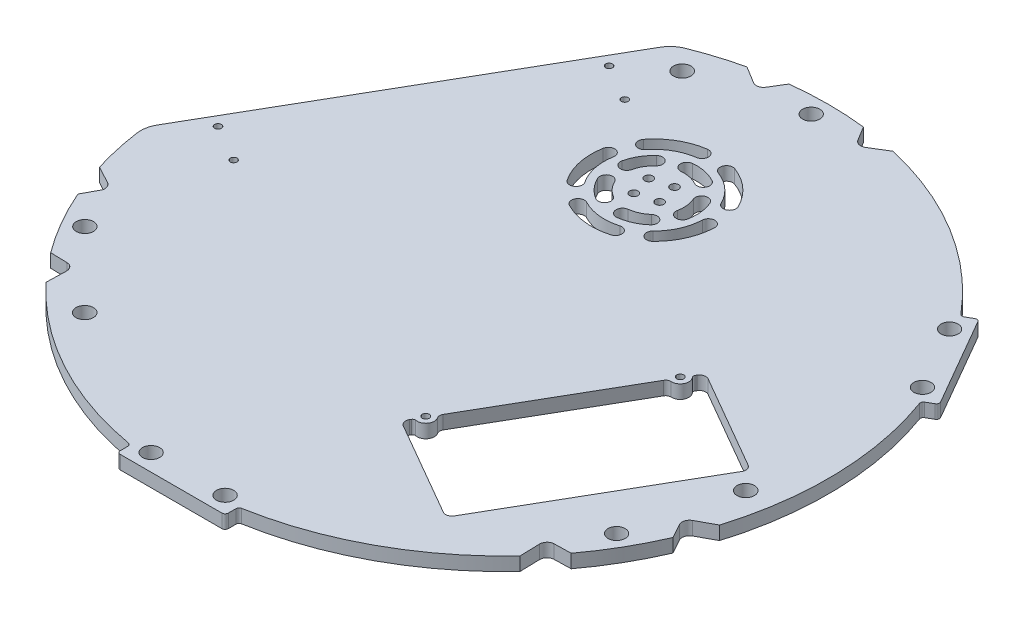
from build123d import *

# Parameters (mm, degrees)
SKETCH1_R               = 152.4
BOSS_EXTRUDE1_DEPTH     = 6.35
SKETCH2_R               = 4.05
CUT_EXTRUDE1_DEPTH      = 7.35
SKETCH3_W               = 50.8
SKETCH3_H               = 6.35
BOSS_EXTRUDE2_DEPTH     = 6.35
SKETCH4_R               = 4.05
CUT_EXTRUDE2_DEPTH      = 7.35
FILLET1_R               = 1.5
CUT_EXTRUDE3_DEPTH      = 1
CUT_EXTRUDE3_DEPTH_BACK = 7.35
SKETCH7_R               = 4.1
CUT_EXTRUDE4_DEPTH      = 7.35
CUT_EXTRUDE5_DEPTH      = 7.35
CIRPATTERN1_COUNT       = 3
CUT_EXTRUDE6_DEPTH      = 7.3500001
FILLET4_R               = 12.7
FILLET1_OF_MIRROR1_R    = 1.5
SKETCH13_R              = 1.6
CUT_EXTRUDE8_DEPTH      = 25.4
SKETCH17_R              = 1.950000002
CUT_EXTRUDE12_DEPTH     = 79.2000001
SKETCH18_R              = 1.6
CUT_EXTRUDE13_DEPTH     = 7.3500001
CUT_EXTRUDE14_DEPTH     = 7.3500001
BOSS_EXTRUDE4_DEPTH     = 6.35
SKETCH22_R              = 1.651
CUT_EXTRUDE15_DEPTH     = 6.35


with BuildPart() as part:
    # Sketch1 → Boss-Extrude1 (new body)
    with BuildSketch(Plane(origin=(0, 0, 0), x_dir=(1, 0, 0), z_dir=(0, 1, 0))):
        Circle(SKETCH1_R)
    extrude(amount=BOSS_EXTRUDE1_DEPTH)

    # Sketch2 → Cut-Extrude1 (cut, through all)
    with BuildSketch(Plane(origin=(0, 6.35, 0), x_dir=(1, 0, 0), z_dir=(0, 1, 0))):
        with Locations((0, 144.337567297)):
            Circle(SKETCH2_R)
        with Locations((125, -72.168783649)):
            Circle(SKETCH2_R)
        with Locations((-125, -72.168783649)):
            Circle(SKETCH2_R)
    extrude(amount=-CUT_EXTRUDE1_DEPTH, mode=Mode.SUBTRACT)

    # Sketch3 → Boss-Extrude2 (add)
    with BuildSketch(Plane(origin=(0, 6.35, 0), x_dir=(1, 0, 0), z_dir=(0, 1, 0))):
        with Locations((0, -153.443426491)):
            Rectangle(SKETCH3_W, SKETCH3_H)
    boss_extrude2 = extrude(amount=-BOSS_EXTRUDE2_DEPTH)

    # Sketch4 → Cut-Extrude2 (cut, through all)
    with BuildSketch(Plane(origin=(0, 6.35, 0), x_dir=(1, 0, 0), z_dir=(0, 1, 0))):
        with Locations((17.4, -148.618426491)):
            Circle(SKETCH4_R)
        with Locations((-17.4, -148.618426491)):
            Circle(SKETCH4_R)
    cut_extrude2 = extrude(amount=-CUT_EXTRUDE2_DEPTH, mode=Mode.SUBTRACT)

    # Fillet1
    fillet1_edges = [part.edges().sort_by_distance(p)[0] for p in [
        (-25.4, 3.175, 156.618426491),
        (-25.4, 3.175, 150.268426491),
        (25.4, 3.175, 150.268426491),
        (25.4, 3.175, 156.618426491),
    ]]
    fillet(fillet1_edges, radius=FILLET1_R)

    # Sketch5 → Cut-Extrude3 (cut, two sides)
    with BuildSketch(Plane.XZ) as cut_extrude3_sk:
        Polygon((349.002117149, -849.311004725), (-39.927688828, -175.664820195), (-166.196580997, 43.039316458), (-555.126386974, 716.685500989), (-1902.418756035, -61.174110966), (-998.290251911, -1627.170616679), align=None)
    extrude(amount=CUT_EXTRUDE3_DEPTH, mode=Mode.SUBTRACT)
    extrude(cut_extrude3_sk.sketch, amount=-CUT_EXTRUDE3_DEPTH_BACK, mode=Mode.SUBTRACT)

    # Sketch7 → Cut-Extrude4 (cut, through all)
    with BuildSketch(Plane(origin=(0, 6.35, 0), x_dir=(1, 0, 0), z_dir=(0, 1, 0))):
        with Locations((-89.990265356, -107.246222037)):
            Circle(SKETCH7_R)
        with Locations((-47.882820066, 131.55696691)):
            Circle(SKETCH7_R)
        with Locations((137.873085422, -24.310744873)):
            Circle(SKETCH7_R)
    extrude(amount=-CUT_EXTRUDE4_DEPTH, mode=Mode.SUBTRACT)

    # Sketch9 → Cut-Extrude5 (cut, through all)
    with BuildSketch(Plane(origin=(0, 0, 0), x_dir=(1, 0, 0), z_dir=(0, 1, 0))):
        with BuildLine():
            Line((-114.489650026, -91.049171744), (-125.485895746, -90.761804289))
            ThreePointArc((-125.485895746, -90.761804289), (-141.107525676, -81.468467934), (-141.344976081, -63.293071388))
            Line((-141.344976081, -63.293071388), (-136.095720736, -53.626359521))
            add(Edge.make_bspline(
                [(-136.095720736, -53.626359521), (-135.878459486, -53.226264313), (-135.609002334, -52.321508604), (-135.827738715, -50.483838058), (-136.77023444, -49.38544542), (-137.535647266, -48.969807981)],
                knots=[0, 0, 0, 0, 0.392699082, 0.785398163, 1.570796327, 1.570796327, 1.570796327, 1.570796327], degree=3))
            Line((-137.535647266, -48.969807981), (-159.97086473, -36.78694924))
            ThreePointArc((-159.97086473, -36.78694924), (-168.082788786, -97.042643352), (-111.843864935, -120.145358102))
            Line((-111.843864935, -120.145358102), (-111.176921363, -94.624460467))
            add(Edge.make_bspline(
                [(-114.489650026, -91.049171744), (-114.034526787, -91.061065586), (-113.116256782, -91.280086701), (-111.634155597, -92.388353236), (-111.154167531, -93.753774797), (-111.176921363, -94.624460467)],
                knots=[0, 0, 0, 0, 0.392699082, 0.785398163, 1.570796327, 1.570796327, 1.570796327, 1.570796327], degree=3))
        make_face()
    cut_extrude5 = extrude(amount=CUT_EXTRUDE5_DEPTH, mode=Mode.SUBTRACT)

    # CirPattern1: Cut-Extrude5 ×3 about axis
    cirpattern1_axis = Axis((0, 6.35, 0), (0, -1, 0))
    for i in range(1, CIRPATTERN1_COUNT):
        add(cut_extrude5.rotate(cirpattern1_axis, i * 360 / CIRPATTERN1_COUNT), mode=Mode.SUBTRACT)

    # Sketch10 → Cut-Extrude6 (cut, through all)
    with BuildSketch(Plane(origin=(0, 6.35, 0), x_dir=(1, 0, 0), z_dir=(0, 1, 0))):
        with BuildLine():
            Line((-19.005119762, -114.312397404), (14.631306921, -133.732397404))
            ThreePointArc((14.631306921, -133.732397404), (17.522407483, -134.113018013), (19.835863709, -132.337840615))
            Line((19.835863709, -132.337840615), (72.525863709, -41.076083564))
            ThreePointArc((72.525863709, -41.076083564), (72.906484319, -38.184983002), (71.131306921, -35.871526776))
            Line((71.131306921, -35.871526776), (37.494880238, -16.451526776))
            ThreePointArc((37.494880238, -16.451526776), (34.603779676, -16.070906166), (32.290323449, -17.846083564))
            Line((32.290323449, -17.846083564), (-20.399676551, -109.107840615))
            ThreePointArc((-20.399676551, -109.107840615), (-20.78029716, -111.998941177), (-19.005119762, -114.312397404))
        make_face()
    extrude(amount=-CUT_EXTRUDE6_DEPTH, mode=Mode.SUBTRACT)

    # Fillet4
    fillet4_edges = [part.edges().sort_by_distance(p)[0] for p in [
        (-60.619909652, 3.175, -139.824842406),
        (-151.40182043, 3.175, 17.414039469),
    ]]
    fillet(fillet4_edges, radius=FILLET4_R)

    # Mirror1: Boss-Extrude2, Cut-Extrude2 across plane
    add(boss_extrude2.mirror(Plane(origin=(0, 0, 0), x_dir=(0.866025404, 0, 0.5), z_dir=(0.5, 0, -0.866025404))))
    add(cut_extrude2.mirror(Plane(origin=(0, 0, 0), x_dir=(0.866025404, 0, 0.5), z_dir=(0.5, 0, -0.866025404))), mode=Mode.SUBTRACT)

    # Fillet1 of Mirror1
    fillet1_of_mirror1_edges = [part.edges().sort_by_distance(p)[0] for p in [
        (122.935536042, 3.175, -100.306258501),
        (117.436274728, 3.175, -97.131258501),
        (142.836274728, 3.175, -53.137167989),
        (148.335536042, 3.175, -56.312167989),
    ]]
    fillet(fillet1_of_mirror1_edges, radius=FILLET1_OF_MIRROR1_R)

    # Sketch13 → Cut-Extrude8 (cut)
    with BuildSketch(Plane(origin=(0, 6.35, 0), x_dir=(1, 0, 0), z_dir=(0, 1, 0))):
        with Locations((-134.469712618, -0.08676846)):
            Circle(SKETCH13_R)
        with Locations((-117.098901351, -10.115811022)):
            Circle(SKETCH13_R)
        with Locations((-67.159712618, 116.497571397)):
            Circle(SKETCH13_R)
        with Locations((-49.788901351, 106.468528836)):
            Circle(SKETCH13_R)
    extrude(amount=-CUT_EXTRUDE8_DEPTH, mode=Mode.SUBTRACT)

    # Sketch17 → Cut-Extrude12 (cut, through all)
    with BuildSketch(Plane(origin=(0, 78.2, 0), x_dir=(1, 0, 0), z_dir=(0, 1, 0))):
        with Locations((-12.025034048, 79.977465694)):
            Circle(SKETCH17_R)
        with Locations((-2.462856222, 82.539643521)):
            Circle(SKETCH17_R)
        with Locations((0.099321605, 72.977465694)):
            Circle(SKETCH17_R)
        with Locations((-9.462856222, 70.415287868)):
            Circle(SKETCH17_R)
        with BuildLine():
            ThreePointArc((15.134436246, 86.828999423), (19.149180016, 85.457200435), (20.520979004, 89.471944204))
            ThreePointArc((20.520979004, 89.471944204), (13.776496666, 98.400238046), (4.192122578, 104.174512569))
            ThreePointArc((4.192122578, 104.174512569), (0.342764035, 102.390573443), (2.126703161, 98.5412149))
            ThreePointArc((2.126703161, 98.5412149), (9.761713028, 93.941369093), (15.134436246, 86.828999423))
        make_face()
        with BuildLine():
            ThreePointArc((-9.28832792, 99.740983012), (-6.7430455, 103.135322035), (-10.137384523, 105.680604455))
            ThreePointArc((-10.137384523, 105.680604455), (-20.712856222, 102.025215106), (-29.166252107, 94.694282633))
            ThreePointArc((-29.166252107, 94.694282633), (-28.659142384, 90.4820576), (-24.446917351, 90.989167323))
            ThreePointArc((-24.446917351, 90.989167323), (-17.712856222, 96.829062683), (-9.28832792, 99.740983012))
        make_face()
        with BuildLine():
            ThreePointArc((10.401459292, 59.611548057), (10.337424979, 55.369390633), (14.579582402, 55.305356319))
            ThreePointArc((14.579582402, 55.305356319), (20.986734779, 64.478734724), (23.516661717, 75.378365113))
            ThreePointArc((23.516661717, 75.378365113), (20.630517579, 78.488055132), (17.52082756, 75.601910994))
            ThreePointArc((17.52082756, 75.601910994), (15.505462033, 66.919154582), (10.401459292, 59.611548057))
        make_face()
        with BuildLine():
            ThreePointArc((-15.464915603, 86.759044732), (-18.087211875, 83.477465694), (-19.61799455, 79.565700989))
            ThreePointArc((-19.61799455, 79.565700989), (-23.205860326, 77.301364624), (-25.470196691, 80.8892304))
            ThreePointArc((-25.470196691, 80.8892304), (-23.283364297, 86.477465694), (-19.537226767, 91.165435748))
            ThreePointArc((-19.537226767, 91.165435748), (-15.297875677, 90.998395822), (-15.464915603, 86.759044732))
        make_face()
        with BuildLine():
            ThreePointArc((0.879208689, 88.691643839), (4.962689344, 89.842810961), (3.811522223, 93.926291616))
            ThreePointArc((3.811522223, 93.926291616), (-1.804622405, 96.040417709), (-7.79511837, 96.393359233))
            ThreePointArc((-7.79511837, 96.393359233), (-10.507663078, 93.13113588), (-7.245439725, 90.418591171))
            ThreePointArc((-7.245439725, 90.418591171), (-3.05209255, 90.171532105), (0.879208689, 88.691643839))
        make_face()
        with BuildLine():
            ThreePointArc((7.767831828, 73.744663895), (10.124521739, 70.216773213), (13.652412421, 72.573463124))
            ThreePointArc((13.652412421, 72.573463124), (13.927581686, 78.56803496), (12.412083964, 84.374400111))
            ThreePointArc((12.412083964, 84.374400111), (8.471302773, 85.946100977), (6.899601908, 82.005319786))
            ThreePointArc((6.899601908, 82.005319786), (7.960450314, 77.94086418), (7.767831828, 73.744663895))
        make_face()
        with BuildLine():
            ThreePointArc((-4.318889229, 62.574323153), (-6.945855418, 59.242799681), (-3.614331946, 56.615833492))
            ThreePointArc((-3.614331946, 56.615833492), (2.17187664, 58.206556542), (7.225743502, 61.442146033))
            ThreePointArc((7.225743502, 61.442146033), (7.502751493, 65.675733941), (3.269163585, 65.952741931))
            ThreePointArc((3.269163585, 65.952741931), (-0.268543219, 63.687829287), (-4.318889229, 62.574323153))
        make_face()
        with BuildLine():
            ThreePointArc((-18.677516794, 70.617652853), (-22.657761096, 72.086548795), (-24.126657039, 68.106304492))
            ThreePointArc((-24.126657039, 68.106304492), (-20.825752731, 63.094853567), (-16.186793513, 59.288192695))
            ThreePointArc((-16.186793513, 59.288192695), (-12.07481197, 60.332993051), (-13.119612326, 64.444974595))
            ThreePointArc((-13.119612326, 64.444974595), (-16.366883778, 67.109637205), (-18.677516794, 70.617652853))
        make_face()
        with BuildLine():
            ThreePointArc((-16.946445499, 55.702221615), (-21.000764651, 54.452223129), (-19.750766166, 50.397903977))
            ThreePointArc((-19.750766166, 50.397903977), (-9.046445888, 47.139069781), (2.101509037, 48.101137303))
            ThreePointArc((2.101509037, 48.101137303), (4.167132407, 51.806970556), (0.461299154, 53.872593925))
            ThreePointArc((0.461299154, 53.872593925), (-8.419275108, 53.106201153), (-16.946445499, 55.702221615))
        make_face()
        with BuildLine():
            ThreePointArc((-29.115403227, 80.503576366), (-31.557075951, 83.97319224), (-35.026691825, 81.531519517))
            ThreePointArc((-35.026691825, 81.531519517), (-34.818210443, 70.344070815), (-30.458322333, 60.039030855))
            ThreePointArc((-30.458322333, 60.039030855), (-26.295552745, 59.219671742), (-25.476193632, 63.38244133))
            ThreePointArc((-25.476193632, 63.38244133), (-28.949324839, 71.59154096), (-29.115403227, 80.503576366))
        make_face()
    extrude(amount=-CUT_EXTRUDE12_DEPTH, mode=Mode.SUBTRACT)

    # Sketch18 → Cut-Extrude13 (cut, through all)
    with BuildSketch(Plane(origin=(0, 6.35, 0), x_dir=(1, 0, 0), z_dir=(0, 1, 0))):
        with Locations((-20.284803569, -98.908874775)):
            Circle(SKETCH18_R)
        with Locations((23.515196431, -23.045049404)):
            Circle(SKETCH18_R)
    extrude(amount=-CUT_EXTRUDE13_DEPTH, mode=Mode.SUBTRACT)

    # Sketch19 → Cut-Extrude14 (cut, through all)
    with BuildSketch(Plane(origin=(0, 6.35, 0), x_dir=(1, 0, 0), z_dir=(0, 1, 0))):
        with BuildLine():
            Line((24.490494366, -130.625783827), (27.030494366, -126.226374775))
            ThreePointArc((27.030494366, -126.226374775), (29.199059695, -125.645309447), (29.780125023, -127.813874775))
            Line((29.780125023, -127.813874775), (27.240125023, -132.213283827))
            ThreePointArc((27.240125023, -132.213283827), (25.071559695, -132.794349155), (24.490494366, -130.625783827))
        make_face()
        with BuildLine():
            Line((29.439829549, -133.483283827), (31.979829549, -129.083874775))
            ThreePointArc((31.979829549, -129.083874775), (34.148394877, -128.502809447), (34.729460206, -130.671374775))
            Line((34.729460206, -130.671374775), (32.189460206, -135.070783827))
            ThreePointArc((32.189460206, -135.070783827), (30.020894877, -135.651849155), (29.439829549, -133.483283827))
        make_face()
        with BuildLine():
            Line((35.920494366, -110.828443096), (38.460494366, -106.429034045))
            ThreePointArc((38.460494366, -106.429034045), (40.629059695, -105.847968716), (41.210125023, -108.016534045))
            Line((41.210125023, -108.016534045), (38.670125023, -112.415943096))
            ThreePointArc((38.670125023, -112.415943096), (36.501559695, -112.997008425), (35.920494366, -110.828443096))
        make_face()
        with BuildLine():
            Line((40.869829549, -113.685943096), (43.409829549, -109.286534045))
            ThreePointArc((43.409829549, -109.286534045), (45.578394877, -108.705468716), (46.159460206, -110.874034045))
            Line((46.159460206, -110.874034045), (43.619460206, -115.273443096))
            ThreePointArc((43.619460206, -115.273443096), (41.450894877, -115.854508425), (40.869829549, -113.685943096))
        make_face()
        with BuildLine():
            Line((47.350494366, -91.031102366), (49.890494366, -86.631693314))
            ThreePointArc((49.890494366, -86.631693314), (52.059059695, -86.050627986), (52.640125023, -88.219193314))
            Line((52.640125023, -88.219193314), (50.100125023, -92.618602366))
            ThreePointArc((50.100125023, -92.618602366), (47.931559695, -93.199667694), (47.350494366, -91.031102366))
        make_face()
        with BuildLine():
            Line((52.299829549, -93.888602366), (54.839829549, -89.489193314))
            ThreePointArc((54.839829549, -89.489193314), (57.008394877, -88.908127986), (57.589460206, -91.076693314))
            Line((57.589460206, -91.076693314), (55.049460206, -95.476102366))
            ThreePointArc((55.049460206, -95.476102366), (52.880894877, -96.057167694), (52.299829549, -93.888602366))
        make_face()
        with BuildLine():
            Line((58.780494366, -71.233761635), (61.320494366, -66.834352584))
            ThreePointArc((61.320494366, -66.834352584), (63.489059695, -66.253287255), (64.070125023, -68.421852584))
            Line((64.070125023, -68.421852584), (61.530125023, -72.821261635))
            ThreePointArc((61.530125023, -72.821261635), (59.361559695, -73.402326964), (58.780494366, -71.233761635))
        make_face()
        with BuildLine():
            Line((63.729829549, -74.091261635), (66.269829549, -69.691852584))
            ThreePointArc((66.269829549, -69.691852584), (68.438394877, -69.110787255), (69.019460206, -71.279352584))
            Line((69.019460206, -71.279352584), (66.479460206, -75.678761635))
            ThreePointArc((66.479460206, -75.678761635), (64.310894877, -76.259826964), (63.729829549, -74.091261635))
        make_face()
        with BuildLine():
            Line((70.210494366, -51.436420905), (72.750494366, -47.037011853))
            ThreePointArc((72.750494366, -47.037011853), (74.919059695, -46.455946525), (75.500125023, -48.624511853))
            Line((75.500125023, -48.624511853), (72.960125023, -53.023920905))
            ThreePointArc((72.960125023, -53.023920905), (70.791559695, -53.604986233), (70.210494366, -51.436420905))
        make_face()
        with BuildLine():
            Line((75.159829549, -54.293920905), (77.699829549, -49.894511853))
            ThreePointArc((77.699829549, -49.894511853), (79.868394877, -49.313446525), (80.449460206, -51.482011853))
            Line((80.449460206, -51.482011853), (77.909460206, -55.881420905))
            ThreePointArc((77.909460206, -55.881420905), (75.740894877, -56.462486233), (75.159829549, -54.293920905))
        make_face()
    extrude(amount=-CUT_EXTRUDE14_DEPTH, mode=Mode.SUBTRACT)

    # Sketch21 → Boss-Extrude4 (add)
    with BuildSketch(Plane.XZ):
        Polygon((-28.020444216, 109.107397404), (28.479555784, 11.246526776), (84.879460206, 43.809026776), (28.379460206, 141.669897404), align=None)
    extrude(amount=-BOSS_EXTRUDE4_DEPTH)

    # Sketch22 → Cut-Extrude15 (cut)
    with BuildSketch(Plane(origin=(0, 6.35, 0), x_dir=(1, 0, 0), z_dir=(0, 1, 0))):
        with Locations((32.392915135, -69.277941854)):
            Circle(SKETCH22_R)
        with Locations((76.192915135, 6.585883517)):
            Circle(SKETCH22_R)
        with BuildLine():
            Line((31.064363032, -78.499061597), (75.608820449, -104.216816077))
            ThreePointArc((75.608820449, -104.216816077), (77.885277584, -104.516517345), (79.70689666, -103.118739866))
            Line((79.70689666, -103.118739866), (129.15689666, -17.468827432))
            ThreePointArc((129.15689666, -17.468827432), (129.456597928, -15.192370296), (128.058820449, -13.37075122))
            Line((128.058820449, -13.37075122), (83.514363032, 12.34700326))
            ThreePointArc((83.514363032, 12.34700326), (81.237905897, 12.646704528), (79.416286821, 11.248927049))
            Line((79.416286821, 11.248927049), (79.101426259, 10.703572559))
            ThreePointArc((79.101426259, 10.703572559), (78.937110411, 9.9470037), (79.24259274, 9.235613033))
            ThreePointArc((79.24259274, 9.235613033), (79.825749573, 4.818367196), (75.990251909, 2.550969935))
            ThreePointArc((75.990251909, 2.550969935), (74.648425274, 2.245044159), (73.663130404, 1.284167831))
            Line((73.663130404, 1.284167831), (35.719443237, -64.436226168))
            ThreePointArc((35.719443237, -64.436226168), (35.379947363, -65.769954719), (35.785921186, -67.084973561))
            ThreePointArc((35.785921186, -67.084973561), (35.74004639, -71.540310605), (31.623020864, -73.243904891))
            ThreePointArc((31.623020864, -73.243904891), (30.854197309, -73.335044768), (30.281147383, -73.855630895))
            Line((30.281147383, -73.855630895), (29.966286821, -74.400985385))
            ThreePointArc((29.966286821, -74.400985385), (29.666585553, -76.677442521), (31.064363032, -78.499061597))
        make_face()
    extrude(amount=-CUT_EXTRUDE15_DEPTH, mode=Mode.SUBTRACT)


solid = part.part
